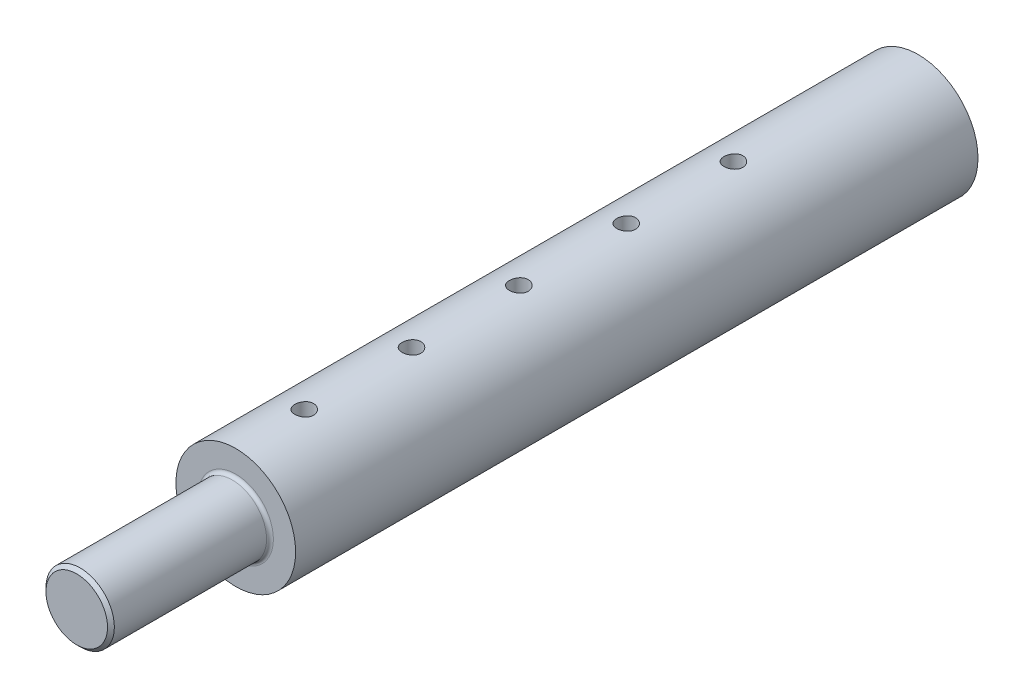
from build123d import *

# Parameters (mm, degrees)
ESQUISSE1_R                               = 17.5
BOSS_EXTRU_1_DEPTH                        = 246
ESQUISSE2_R                               = 12
ENL_V_MAT_EXTRU_1_DEPTH                   = 44
TROU_TARAUD_M62_REACH                     = 37
TROU_TARAUD_M62_BORE_R                    = 2.5
ESQUISSE11_R                              = 17.5
ESQUISSE11_R_2                            = 10
ENL_V_MAT_EXTRU_3_DEPTH                   = 46.5
CONG_1_R                                  = 1
CHANFREIN1_SIZE                           = 1
TROU_POUR_TARAUDAGE_POUR_TROU_TARAUD_M6_D = 5.5


with BuildPart() as part:
    # Esquisse1 → Boss.-Extru.1 (new body)
    with BuildSketch(Plane.XY):
        Circle(ESQUISSE1_R)
    extrude(amount=BOSS_EXTRU_1_DEPTH)

    # Esquisse2 → Enlèv. mat.-Extru.1 (cut)
    with BuildSketch(Plane(origin=(0, 0, 0), x_dir=(-1, 0, 0), z_dir=(0, 0, -1))):
        Circle(ESQUISSE2_R)
    extrude(amount=-ENL_V_MAT_EXTRU_1_DEPTH, mode=Mode.SUBTRACT)

    # Trou taraudé M62 bore (on position points) → Trou taraudé M62 (cut, up to next)
    with BuildSketch(Plane(origin=(-17.5, 0, 32), x_dir=(0, 0, -1), z_dir=(-1, 0, 0)), mode=Mode.PRIVATE) as trou_taraud_m62_sk1:
        Circle(TROU_TARAUD_M62_BORE_R)
    trou_taraud_m62_tool1 = extrude(trou_taraud_m62_sk1.sketch, amount=-TROU_TARAUD_M62_REACH, mode=Mode.PRIVATE) & part.part
    add(trou_taraud_m62_tool1.solids().sort_by_distance((-17.5, 0, 32))[0], mode=Mode.SUBTRACT)
    # Trou taraudé M62 bore (on position points) → Trou taraudé M62 (cut, up to next)
    with BuildSketch(Plane(origin=(-17.5, 0, 32), x_dir=(0, 0, -1), z_dir=(-1, 0, 0)), mode=Mode.PRIVATE) as trou_taraud_m62_sk2:
        with Locations((7, 0)):
            Circle(TROU_TARAUD_M62_BORE_R)
    trou_taraud_m62_tool2 = extrude(trou_taraud_m62_sk2.sketch, amount=-TROU_TARAUD_M62_REACH, mode=Mode.PRIVATE) & part.part
    add(trou_taraud_m62_tool2.solids().sort_by_distance((-17.5, 0, 25))[0], mode=Mode.SUBTRACT)
    # Trou taraudé M62 bore (on position points) → Trou taraudé M62 (cut, up to next)
    with BuildSketch(Plane(origin=(-17.5, 0, 32), x_dir=(0, 0, -1), z_dir=(-1, 0, 0)), mode=Mode.PRIVATE) as trou_taraud_m62_sk3:
        with Locations((14, 0)):
            Circle(TROU_TARAUD_M62_BORE_R)
    trou_taraud_m62_tool3 = extrude(trou_taraud_m62_sk3.sketch, amount=-TROU_TARAUD_M62_REACH, mode=Mode.PRIVATE) & part.part
    add(trou_taraud_m62_tool3.solids().sort_by_distance((-17.5, 0, 18))[0], mode=Mode.SUBTRACT)

    # Esquisse11 → Enlèv. mat.-Extru.3 (cut)
    with BuildSketch(Plane.XY.offset(246)):
        Circle(ESQUISSE11_R)
        Circle(ESQUISSE11_R_2, mode=Mode.SUBTRACT)
    extrude(amount=-ENL_V_MAT_EXTRU_3_DEPTH, mode=Mode.SUBTRACT)

    # Congé1
    cong_1_edges = [part.edges().sort_by_distance(p)[0] for p in [
        (-10, 0, 199.5),
    ]]
    fillet(cong_1_edges, radius=CONG_1_R)

    # Chanfrein1
    chanfrein1_edges = [part.edges().sort_by_distance(p)[0] for p in [
        (-10, 0, 246),
        (12, 0, 0),
    ]]
    chamfer(chanfrein1_edges, length=CHANFREIN1_SIZE)

    # Trou pour taraudage pour trou taraudé M62 (through all)
    with Locations(Plane(origin=(0, 17.5, 0), x_dir=(1, 0, 0), z_dir=(0, 1, 0))):
        with Locations((0, -54), (0, -116.75), (0, -179.5), (0, -85.375), (0, -148.125)):
            Hole(TROU_POUR_TARAUDAGE_POUR_TROU_TARAUD_M6_D / 2)


solid = part.part
